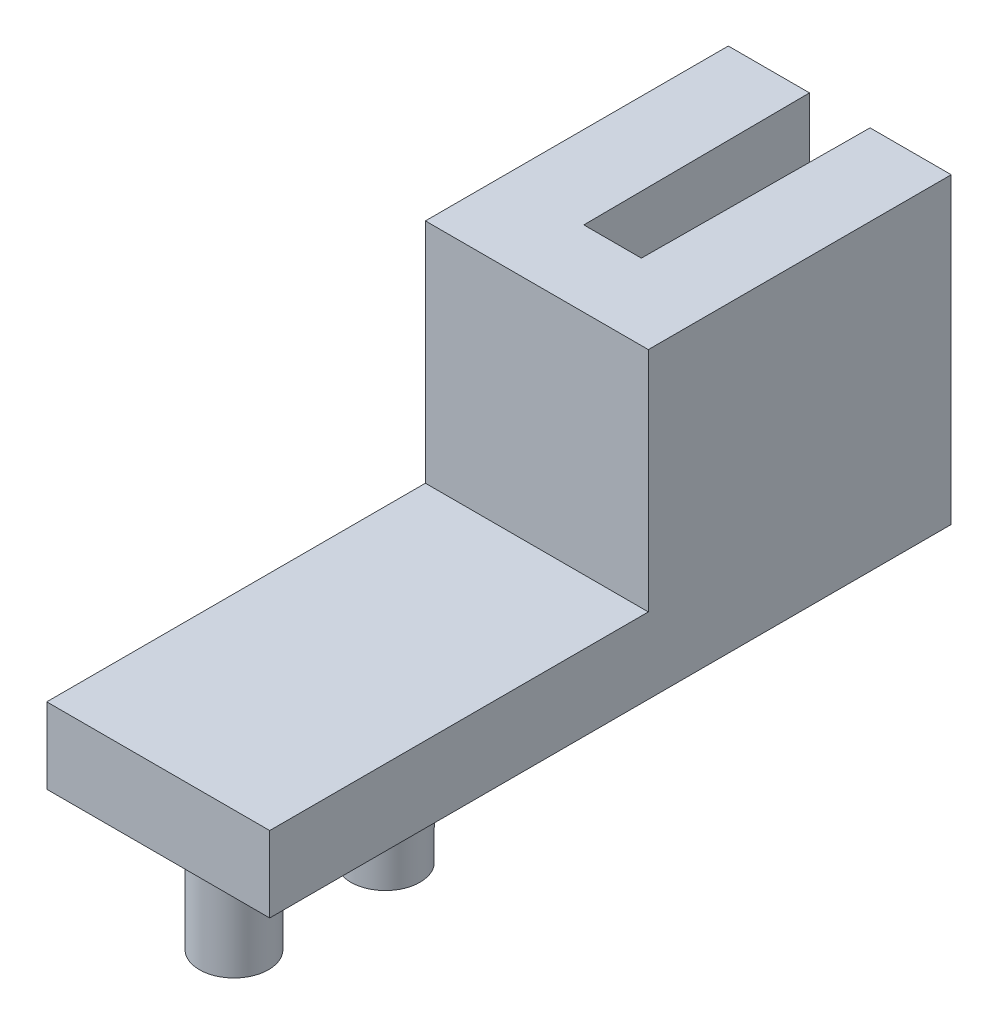
from build123d import *

# Parameters (mm, degrees)
SKETCH2_W           = 15.875
SKETCH2_H           = 3.175
BOSS_EXTRUDE1_DEPTH = 9.3472
SKETCH3_W           = 2.413
SKETCH3_H           = 9.525
CUT_EXTRUDE1_DEPTH  = 13.7
SKETCH4_R           = 1.45
BOSS_EXTRUDE2_DEPTH = 5.08


with BuildPart() as part:
    # Sketch2 → Boss-Extrude1 (new body)
    with BuildSketch(Plane(origin=(0, 0, 0), x_dir=(0, 0, -1), z_dir=(1, 0, 0))):
        with Locations((-7.9375, -1.5875)):
            Rectangle(SKETCH2_W, SKETCH2_H)
        Polygon((0, 9.525), (0, 0), (0, -3.175), (12.7, -3.175), (12.7, 9.525), align=None)
    extrude(amount=BOSS_EXTRUDE1_DEPTH)

    # Sketch3 → Cut-Extrude1 (cut, through all)
    with BuildSketch(Plane(origin=(0, 9.525, 0), x_dir=(1, 0, 0), z_dir=(0, 1, 0))):
        with Locations((4.6736, 7.9375)):
            Rectangle(SKETCH3_W, SKETCH3_H)
        Polygon((3.4671, 3.175), (3.4671, 12.7), (3.4036, 12.7), align=None)
        Polygon((5.9436, 12.7), (5.8801, 12.7), (5.8801, 3.175), align=None)
    extrude(amount=-CUT_EXTRUDE1_DEPTH, mode=Mode.SUBTRACT)

    # Sketch4 → Boss-Extrude2 (add)
    with BuildSketch(Plane.XZ.offset(3.175)):
        with Locations((4.6736, 12.7)):
            Circle(SKETCH4_R)
        with Locations((4.6736, 6.35)):
            Circle(SKETCH4_R)
    extrude(amount=BOSS_EXTRUDE2_DEPTH)


solid = part.part
